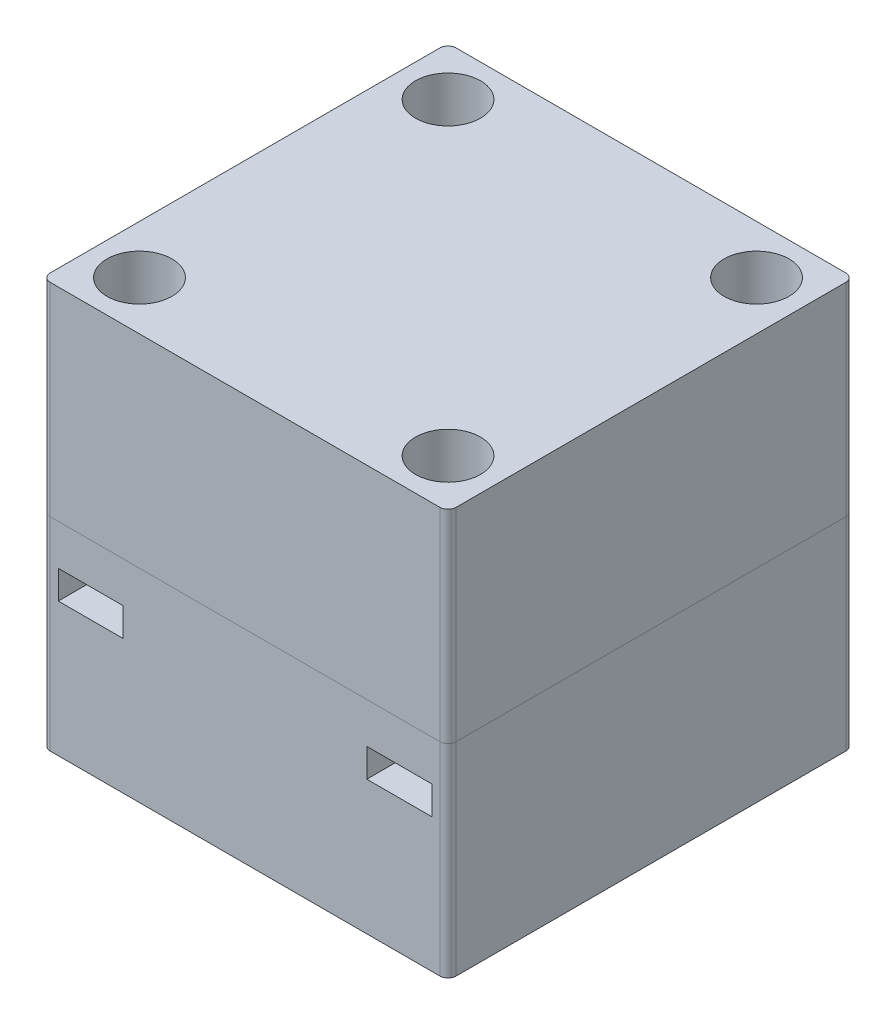
from build123d import *

# Parameters (mm, degrees)
SKETCH1_W           = 50
SKETCH1_H           = 50
BOSS_EXTRUDE1_DEPTH = 25
SHELL1_T            = -6
BOSS_EXTRUDE2_REACH = 45.301
FILLET2_R           = 2
CUT_EXTRUDE1_DEPTH  = 5
SKETCH3_3_R         = 2
CUT_EXTRUDE2_DEPTH  = 44.301270189
CUT_EXTRUDE3_START  = -5
CUT_EXTRUDE3_DEPTH  = 3.5
SHELL2_T            = -6
BOSS_EXTRUDE4_REACH = 45.301
FILLET3_R           = 2
BOSS_EXTRUDE3_DEPTH = 3
SKETCH3_6_R         = 2
CUT_EXTRUDE4_DEPTH  = 44.301270189
CUT_EXTRUDE5_START  = -10
SKETCH4_R           = 4
CUT_EXTRUDE5_DEPTH  = 34.301270189
FILLET4_R           = 1
FILLET5_R           = 1


with BuildPart() as part:
    # Sketch1 → Boss-Extrude1 (new, symmetric)
    with BuildSketch(Plane(origin=(0, 0, 0), x_dir=(1, 0, 0), z_dir=(0, 1, 0))):
        Rectangle(SKETCH1_W, SKETCH1_H)
    extrude(amount=BOSS_EXTRUDE1_DEPTH, both=True)


with BuildPart() as body_2:
    # Split1: the piece on the far side of the plane
    add(part.part)
    split(bisect_by=Plane.ZX, keep=Keep.BOTTOM)

    # Shell1
    shell1_openings = [body_2.faces().sort_by_distance(p)[0] for p in [
        (0, 0, 0),
    ]]
    offset(amount=SHELL1_T, openings=shell1_openings, kind=Kind.INTERSECTION)

    # Sketch2 → Boss-Extrude2 (add, up to next)
    with BuildSketch(Plane(origin=(0, 0, 0), x_dir=(1, 0, 0), z_dir=(0, 1, 0)), mode=Mode.PRIVATE) as boss_extrude2_sk1:
        with BuildLine():
            Line((-19, 9), (-19, 19))
            Line((-19, 19), (-9, 19))
            ThreePointArc((-9, 19), (-11.928932188, 11.928932188), (-19, 9))
        make_face()
    boss_extrude2_tool1 = extrude(boss_extrude2_sk1.sketch, amount=-BOSS_EXTRUDE2_REACH, mode=Mode.PRIVATE) - body_2.part
    # Sketch2 → Boss-Extrude2 (add, up to next)
    with BuildSketch(Plane(origin=(0, 0, 0), x_dir=(1, 0, 0), z_dir=(0, 1, 0)), mode=Mode.PRIVATE) as boss_extrude2_sk2:
        with BuildLine():
            Line((19, 19), (9, 19))
            ThreePointArc((9, 19), (11.928932188, 11.928932188), (19, 9))
            Line((19, 9), (19, 19))
        make_face()
    boss_extrude2_tool2 = extrude(boss_extrude2_sk2.sketch, amount=-BOSS_EXTRUDE2_REACH, mode=Mode.PRIVATE) - body_2.part
    # Sketch2 → Boss-Extrude2 (add, up to next)
    with BuildSketch(Plane(origin=(0, 0, 0), x_dir=(1, 0, 0), z_dir=(0, 1, 0)), mode=Mode.PRIVATE) as boss_extrude2_sk3:
        with BuildLine():
            Line((19, -9), (19, -19))
            Line((19, -19), (9, -19))
            ThreePointArc((9, -19), (11.928932188, -11.928932188), (19, -9))
        make_face()
    boss_extrude2_tool3 = extrude(boss_extrude2_sk3.sketch, amount=-BOSS_EXTRUDE2_REACH, mode=Mode.PRIVATE) - body_2.part
    # Sketch2 → Boss-Extrude2 (add, up to next)
    with BuildSketch(Plane(origin=(0, 0, 0), x_dir=(1, 0, 0), z_dir=(0, 1, 0)), mode=Mode.PRIVATE) as boss_extrude2_sk4:
        with BuildLine():
            Line((-19, -19), (-9, -19))
            ThreePointArc((-9, -19), (-11.928932188, -11.928932188), (-19, -9))
            Line((-19, -9), (-19, -19))
        make_face()
    boss_extrude2_tool4 = extrude(boss_extrude2_sk4.sketch, amount=-BOSS_EXTRUDE2_REACH, mode=Mode.PRIVATE) - body_2.part
    add(boss_extrude2_tool1.solids().sort_by_distance((-14.755868, 0, -14.755868))[0])
    add(boss_extrude2_tool2.solids().sort_by_distance((14.755868, 0, -14.755868))[0])
    add(boss_extrude2_tool3.solids().sort_by_distance((14.755868, 0, 14.755868))[0])
    add(boss_extrude2_tool4.solids().sort_by_distance((-14.755868, 0, 14.755868))[0])

    # Fillet2
    fillet2_edges = [body_2.edges().sort_by_distance(p)[0] for p in [
        (-9, -9.5, -19),
        (-19, -9.5, -9),
        (19, -9.5, -9),
        (9, -9.5, -19),
        (19, -9.5, 9),
        (9, -9.5, 19),
        (-19, -9.5, 9),
        (-9, -9.5, 19),
    ]]
    fillet(fillet2_edges, radius=FILLET2_R)

    # Sketch3 → Cut-Extrude1 (cut)
    with BuildSketch(Plane(origin=(0, 0, 0), x_dir=(1, 0, 0), z_dir=(0, 1, 0))):
        with BuildLine():
            ThreePointArc((-18.083333333, 13.576926865), (-15.110912703, 15.110912703), (-13.576926865, 18.083333333))
            ThreePointArc((-13.576926865, 18.083333333), (-11.363572392, 21.964457003), (-7.167840434, 23.5))
            Line((-7.167840434, 23.5), (7.167840434, 23.5))
            ThreePointArc((7.167840434, 23.5), (11.363572392, 21.964457003), (13.576926865, 18.083333333))
            ThreePointArc((13.576926865, 18.083333333), (15.110912703, 15.110912703), (18.083333333, 13.576926865))
            ThreePointArc((18.083333333, 13.576926865), (21.964457003, 11.363572392), (23.5, 7.167840434))
            Line((23.5, 7.167840434), (23.5, -7.167840434))
            ThreePointArc((23.5, -7.167840434), (21.964457003, -11.363572392), (18.083333333, -13.576926865))
            ThreePointArc((18.083333333, -13.576926865), (15.110912703, -15.110912703), (13.576926865, -18.083333333))
            ThreePointArc((13.576926865, -18.083333333), (11.363572392, -21.964457003), (7.167840434, -23.5))
            Line((7.167840434, -23.5), (-7.167840434, -23.5))
            ThreePointArc((-7.167840434, -23.5), (-11.363572392, -21.964457003), (-13.576926865, -18.083333333))
            ThreePointArc((-13.576926865, -18.083333333), (-15.110912703, -15.110912703), (-18.083333333, -13.576926865))
            ThreePointArc((-18.083333333, -13.576926865), (-21.964457003, -11.363572392), (-23.5, -7.167840434))
            Line((-23.5, -7.167840434), (-23.5, 7.167840434))
            ThreePointArc((-23.5, 7.167840434), (-21.964457003, 11.363572392), (-18.083333333, 13.576926865))
        make_face()
        with BuildLine():
            ThreePointArc((-17.583333333, 10.618886974), (-19.673169155, 9.427080719), (-20.5, 7.167840434))
            Line((-20.5, 7.167840434), (-20.5, -7.167840434))
            ThreePointArc((-20.5, -7.167840434), (-19.673169155, -9.427080719), (-17.583333333, -10.618886974))
            ThreePointArc((-17.583333333, -10.618886974), (-12.98959236, -12.98959236), (-10.618886974, -17.583333333))
            ThreePointArc((-10.618886974, -17.583333333), (-9.427080719, -19.673169155), (-7.167840434, -20.5))
            Line((-7.167840434, -20.5), (7.167840434, -20.5))
            ThreePointArc((7.167840434, -20.5), (9.427080719, -19.673169155), (10.618886974, -17.583333333))
            ThreePointArc((10.618886974, -17.583333333), (12.98959236, -12.98959236), (17.583333333, -10.618886974))
            ThreePointArc((17.583333333, -10.618886974), (19.673169155, -9.427080719), (20.5, -7.167840434))
            Line((20.5, -7.167840434), (20.5, 7.167840434))
            ThreePointArc((20.5, 7.167840434), (19.673169155, 9.427080719), (17.583333333, 10.618886974))
            ThreePointArc((17.583333333, 10.618886974), (12.98959236, 12.98959236), (10.618886974, 17.583333333))
            ThreePointArc((10.618886974, 17.583333333), (9.427080719, 19.673169155), (7.167840434, 20.5))
            Line((7.167840434, 20.5), (-7.167840434, 20.5))
            ThreePointArc((-7.167840434, 20.5), (-9.427080719, 19.673169155), (-10.618886974, 17.583333333))
            ThreePointArc((-10.618886974, 17.583333333), (-12.98959236, 12.98959236), (-17.583333333, 10.618886974))
        make_face(mode=Mode.SUBTRACT)
    extrude(amount=-CUT_EXTRUDE1_DEPTH, mode=Mode.SUBTRACT)

    # Sketch3_3 → Cut-Extrude2 (cut, through all)
    with BuildSketch(Plane(origin=(0, 0, 0), x_dir=(1, 0, 0), z_dir=(0, 1, 0))):
        with Locations(Location((-19, -19, 0), (0, 0, 270))):
            Circle(SKETCH3_3_R)
        with Locations(Location((19, 19, 0), (0, 0, 270))):
            Circle(SKETCH3_3_R)
        with Locations(Location((19, -19, 0), (0, 0, 270))):
            Circle(SKETCH3_3_R)
        with Locations(Location((-19, 19, 0), (0, 0, 270))):
            Circle(SKETCH3_3_R)
    extrude(amount=-CUT_EXTRUDE2_DEPTH, mode=Mode.SUBTRACT)

    # Sketch3_4 → Cut-Extrude3 (cut)
    with BuildSketch(Plane(origin=(0, 0, 0), x_dir=(1, 0, 0), z_dir=(0, 1, 0)).offset(CUT_EXTRUDE3_START)):
        with BuildLine():
            Line((-23, 19), (-23, 25))
            Line((-23, 25), (-15, 25))
            Line((-15, 25), (-15, 19))
            ThreePointArc((-15, 19), (-19, 15), (-23, 19))
        make_face()
        with BuildLine():
            Line((15, 25), (15, 19))
            ThreePointArc((15, 19), (19, 15), (23, 19))
            Line((23, 19), (23, 25))
            Line((23, 25), (15, 25))
        make_face()
        with BuildLine():
            Line((23, -19), (23, -25))
            Line((23, -25), (15, -25))
            Line((15, -25), (15, -19))
            ThreePointArc((15, -19), (19, -15), (23, -19))
        make_face()
        with BuildLine():
            Line((-15, -25), (-15, -19))
            ThreePointArc((-15, -19), (-19, -15), (-23, -19))
            Line((-23, -19), (-23, -25))
            Line((-23, -25), (-15, -25))
        make_face()
    extrude(amount=-CUT_EXTRUDE3_DEPTH, mode=Mode.SUBTRACT)

    # Fillet4
    fillet4_edges = [body_2.edges().sort_by_distance(p)[0] for p in [
        (25, -12.5, 25),
        (-25, -12.5, 25),
        (-25, -12.5, -25),
        (25, -12.5, -25),
    ]]
    fillet(fillet4_edges, radius=FILLET4_R)


with BuildPart() as part_1:
    add(part.part)

    # Split1
    split(bisect_by=Plane.ZX, keep=Keep.TOP)

    # Shell2
    shell2_openings = [part_1.faces().sort_by_distance(p)[0] for p in [
        (0, 0, 0),
    ]]
    offset(amount=SHELL2_T, openings=shell2_openings, kind=Kind.INTERSECTION)

    # Sketch2_2 → Boss-Extrude4 (add, up to next)
    with BuildSketch(Plane(origin=(0, 0, 0), x_dir=(1, 0, 0), z_dir=(0, 1, 0)), mode=Mode.PRIVATE) as boss_extrude4_sk1:
        with BuildLine():
            Line((-19, 9), (-19, 19))
            Line((-19, 19), (-9, 19))
            ThreePointArc((-9, 19), (-11.928932188, 11.928932188), (-19, 9))
        make_face()
    boss_extrude4_tool1 = extrude(boss_extrude4_sk1.sketch, amount=BOSS_EXTRUDE4_REACH, mode=Mode.PRIVATE) - part_1.part
    # Sketch2_2 → Boss-Extrude4 (add, up to next)
    with BuildSketch(Plane(origin=(0, 0, 0), x_dir=(1, 0, 0), z_dir=(0, 1, 0)), mode=Mode.PRIVATE) as boss_extrude4_sk2:
        with BuildLine():
            Line((19, 19), (9, 19))
            ThreePointArc((9, 19), (11.928932188, 11.928932188), (19, 9))
            Line((19, 9), (19, 19))
        make_face()
    boss_extrude4_tool2 = extrude(boss_extrude4_sk2.sketch, amount=BOSS_EXTRUDE4_REACH, mode=Mode.PRIVATE) - part_1.part
    # Sketch2_2 → Boss-Extrude4 (add, up to next)
    with BuildSketch(Plane(origin=(0, 0, 0), x_dir=(1, 0, 0), z_dir=(0, 1, 0)), mode=Mode.PRIVATE) as boss_extrude4_sk3:
        with BuildLine():
            Line((19, -9), (19, -19))
            Line((19, -19), (9, -19))
            ThreePointArc((9, -19), (11.928932188, -11.928932188), (19, -9))
        make_face()
    boss_extrude4_tool3 = extrude(boss_extrude4_sk3.sketch, amount=BOSS_EXTRUDE4_REACH, mode=Mode.PRIVATE) - part_1.part
    # Sketch2_2 → Boss-Extrude4 (add, up to next)
    with BuildSketch(Plane(origin=(0, 0, 0), x_dir=(1, 0, 0), z_dir=(0, 1, 0)), mode=Mode.PRIVATE) as boss_extrude4_sk4:
        with BuildLine():
            Line((-19, -19), (-9, -19))
            ThreePointArc((-9, -19), (-11.928932188, -11.928932188), (-19, -9))
            Line((-19, -9), (-19, -19))
        make_face()
    boss_extrude4_tool4 = extrude(boss_extrude4_sk4.sketch, amount=BOSS_EXTRUDE4_REACH, mode=Mode.PRIVATE) - part_1.part
    add(boss_extrude4_tool1.solids().sort_by_distance((-14.755868, 0, -14.755868))[0])
    add(boss_extrude4_tool2.solids().sort_by_distance((14.755868, 0, -14.755868))[0])
    add(boss_extrude4_tool3.solids().sort_by_distance((14.755868, 0, 14.755868))[0])
    add(boss_extrude4_tool4.solids().sort_by_distance((-14.755868, 0, 14.755868))[0])

    # Fillet3
    fillet3_edges = [part_1.edges().sort_by_distance(p)[0] for p in [
        (-19, 9.5, -9),
        (-9, 9.5, -19),
        (9, 9.5, -19),
        (19, 9.5, -9),
        (19, 9.5, 9),
        (9, 9.5, 19),
        (-9, 9.5, 19),
        (-19, 9.5, 9),
    ]]
    fillet(fillet3_edges, radius=FILLET3_R)

    # Sketch3_5 → Boss-Extrude3 (add)
    with BuildSketch(Plane(origin=(0, 0, 0), x_dir=(1, 0, 0), z_dir=(0, 1, 0))):
        with BuildLine():
            ThreePointArc((-18.083333333, 13.576926865), (-15.110912703, 15.110912703), (-13.576926865, 18.083333333))
            ThreePointArc((-13.576926865, 18.083333333), (-11.363572392, 21.964457003), (-7.167840434, 23.5))
            Line((-7.167840434, 23.5), (7.167840434, 23.5))
            ThreePointArc((7.167840434, 23.5), (11.363572392, 21.964457003), (13.576926865, 18.083333333))
            ThreePointArc((13.576926865, 18.083333333), (15.110912703, 15.110912703), (18.083333333, 13.576926865))
            ThreePointArc((18.083333333, 13.576926865), (21.964457003, 11.363572392), (23.5, 7.167840434))
            Line((23.5, 7.167840434), (23.5, -7.167840434))
            ThreePointArc((23.5, -7.167840434), (21.964457003, -11.363572392), (18.083333333, -13.576926865))
            ThreePointArc((18.083333333, -13.576926865), (15.110912703, -15.110912703), (13.576926865, -18.083333333))
            ThreePointArc((13.576926865, -18.083333333), (11.363572392, -21.964457003), (7.167840434, -23.5))
            Line((7.167840434, -23.5), (-7.167840434, -23.5))
            ThreePointArc((-7.167840434, -23.5), (-11.363572392, -21.964457003), (-13.576926865, -18.083333333))
            ThreePointArc((-13.576926865, -18.083333333), (-15.110912703, -15.110912703), (-18.083333333, -13.576926865))
            ThreePointArc((-18.083333333, -13.576926865), (-21.964457003, -11.363572392), (-23.5, -7.167840434))
            Line((-23.5, -7.167840434), (-23.5, 7.167840434))
            ThreePointArc((-23.5, 7.167840434), (-21.964457003, 11.363572392), (-18.083333333, 13.576926865))
        make_face()
        with BuildLine():
            ThreePointArc((-17.583333333, 10.618886974), (-19.673169155, 9.427080719), (-20.5, 7.167840434))
            Line((-20.5, 7.167840434), (-20.5, -7.167840434))
            ThreePointArc((-20.5, -7.167840434), (-19.673169155, -9.427080719), (-17.583333333, -10.618886974))
            ThreePointArc((-17.583333333, -10.618886974), (-12.98959236, -12.98959236), (-10.618886974, -17.583333333))
            ThreePointArc((-10.618886974, -17.583333333), (-9.427080719, -19.673169155), (-7.167840434, -20.5))
            Line((-7.167840434, -20.5), (7.167840434, -20.5))
            ThreePointArc((7.167840434, -20.5), (9.427080719, -19.673169155), (10.618886974, -17.583333333))
            ThreePointArc((10.618886974, -17.583333333), (12.98959236, -12.98959236), (17.583333333, -10.618886974))
            ThreePointArc((17.583333333, -10.618886974), (19.673169155, -9.427080719), (20.5, -7.167840434))
            Line((20.5, -7.167840434), (20.5, 7.167840434))
            ThreePointArc((20.5, 7.167840434), (19.673169155, 9.427080719), (17.583333333, 10.618886974))
            ThreePointArc((17.583333333, 10.618886974), (12.98959236, 12.98959236), (10.618886974, 17.583333333))
            ThreePointArc((10.618886974, 17.583333333), (9.427080719, 19.673169155), (7.167840434, 20.5))
            Line((7.167840434, 20.5), (-7.167840434, 20.5))
            ThreePointArc((-7.167840434, 20.5), (-9.427080719, 19.673169155), (-10.618886974, 17.583333333))
            ThreePointArc((-10.618886974, 17.583333333), (-12.98959236, 12.98959236), (-17.583333333, 10.618886974))
        make_face(mode=Mode.SUBTRACT)
    extrude(amount=-BOSS_EXTRUDE3_DEPTH)

    # Sketch3_6 → Cut-Extrude4 (cut, through all)
    with BuildSketch(Plane(origin=(0, 0, 0), x_dir=(1, 0, 0), z_dir=(0, 1, 0))):
        with Locations(Location((-19, 19, 0), (0, 0, 270))):
            Circle(SKETCH3_6_R)
        with Locations(Location((19, 19, 0), (0, 0, 270))):
            Circle(SKETCH3_6_R)
        with Locations(Location((19, -19, 0), (0, 0, 270))):
            Circle(SKETCH3_6_R)
        with Locations(Location((-19, -19, 0), (0, 0, 270))):
            Circle(SKETCH3_6_R)
    extrude(amount=CUT_EXTRUDE4_DEPTH, mode=Mode.SUBTRACT)

    # Sketch4 → Cut-Extrude5 (cut, through all)
    with BuildSketch(Plane(origin=(0, 0, 0), x_dir=(-1, 0, 0), z_dir=(0, -1, 0)).offset(CUT_EXTRUDE5_START)):
        with Locations(Location((19, -19, 0), (0, 0, 90))):
            Circle(SKETCH4_R)
        with Locations(Location((-19, -19, 0), (0, 0, 90))):
            Circle(SKETCH4_R)
        with Locations(Location((-19, 19, 0), (0, 0, 90))):
            Circle(SKETCH4_R)
        with Locations(Location((19, 19, 0), (0, 0, 90))):
            Circle(SKETCH4_R)
    extrude(amount=-CUT_EXTRUDE5_DEPTH, mode=Mode.SUBTRACT)

    # Fillet5
    fillet5_edges = [part_1.edges().sort_by_distance(p)[0] for p in [
        (25, 12.5, 25),
        (-25, 12.5, 25),
        (-25, 12.5, -25),
        (25, 12.5, -25),
    ]]
    fillet(fillet5_edges, radius=FILLET5_R)


solid = Compound([body_2.part, part_1.part])
